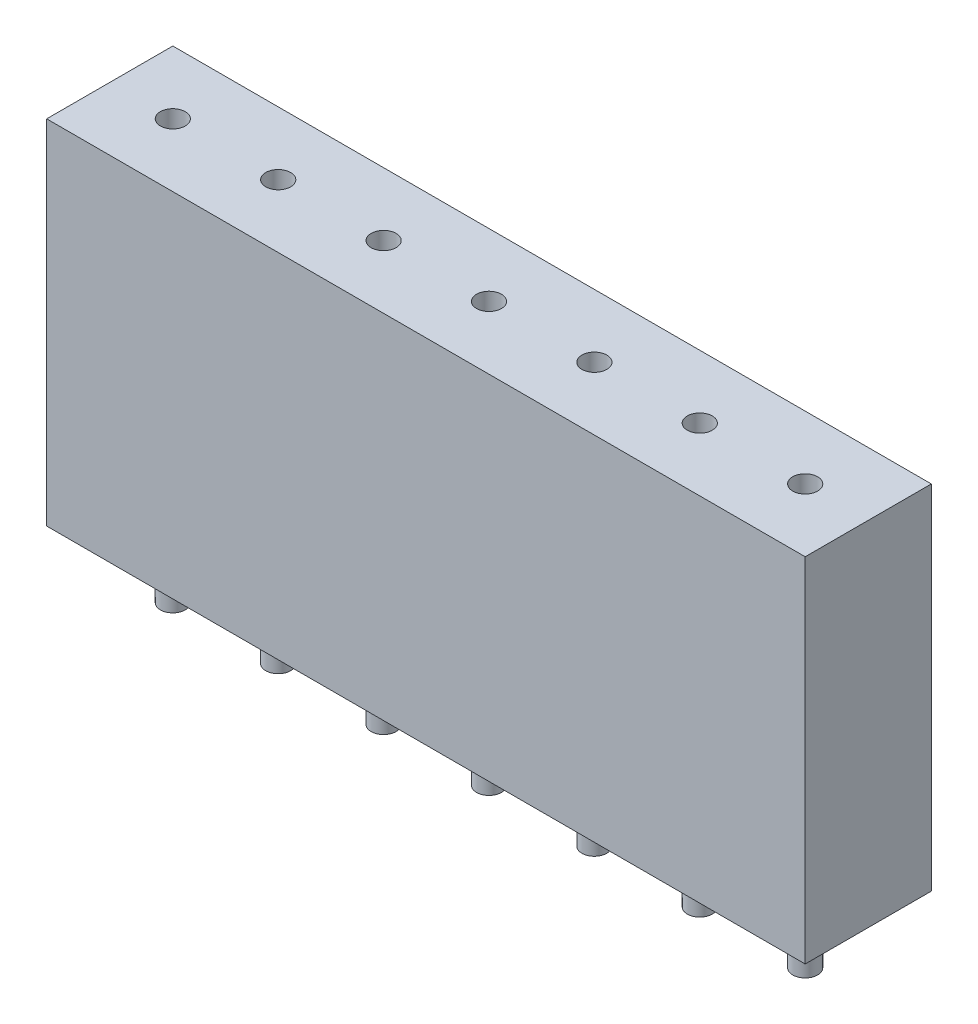
from build123d import *

# Parameters (mm, degrees)
SKETCH_1_W          = 18.28
SKETCH_1_H          = 3.04
EXTRUDE_1_DEPTH     = 8.5
SKETCH_2_R          = 0.3
CUT_EXTRUDE_1_DEPTH = 8.5
SKETCH_3_R          = 0.3
EXTRUDE_2_DEPTH     = 1.6
EXTRUDE_2_2_DEPTH   = 1.6
EXTRUDE_2_3_DEPTH   = 1.6
EXTRUDE_2_4_DEPTH   = 1.6
EXTRUDE_2_5_DEPTH   = 1.6
EXTRUDE_2_6_DEPTH   = 1.6
EXTRUDE_2_7_DEPTH   = 1.6


with BuildPart() as part:
    # Эскиз1 → Бобышка-Вытянуть1 (new body)
    with BuildSketch(Plane(origin=(0, 0, 0), x_dir=(1, 0, 0), z_dir=(0, 1, 0))):
        Rectangle(SKETCH_1_W, SKETCH_1_H)
    extrude(amount=EXTRUDE_1_DEPTH)

    # Эскиз2 → Вырез-Вытянуть1 (cut)
    with BuildSketch(Plane(origin=(0, 8.5, 0), x_dir=(1, 0, 0), z_dir=(0, 1, 0))):
        with Locations((-7.62, 0)):
            Circle(SKETCH_2_R)
        with Locations((-5.08, 0)):
            Circle(SKETCH_2_R)
        with Locations((-2.54, 0)):
            Circle(SKETCH_2_R)
        Circle(SKETCH_2_R)
        with Locations((2.54, 0)):
            Circle(SKETCH_2_R)
        with Locations((5.08, 0)):
            Circle(SKETCH_2_R)
        with Locations((7.62, 0)):
            Circle(SKETCH_2_R)
    extrude(amount=-CUT_EXTRUDE_1_DEPTH, mode=Mode.SUBTRACT)


with BuildPart() as body_2:
    # Эскиз3 → Бобышка-Вытянуть2 (new body)
    with BuildSketch(Plane.XZ):
        with Locations((-7.62, 0)):
            Circle(SKETCH_3_R)
    extrude(amount=EXTRUDE_2_DEPTH)


with BuildPart() as body_3:
    # Эскиз3 → Extrude 2 2 (new body)
    with BuildSketch(Plane.XZ):
        with Locations((-5.08, 0)):
            Circle(SKETCH_3_R)
    extrude(amount=EXTRUDE_2_2_DEPTH)


with BuildPart() as body_4:
    # Эскиз3 → Extrude 2 3 (new body)
    with BuildSketch(Plane.XZ):
        with Locations((-2.54, 0)):
            Circle(SKETCH_3_R)
    extrude(amount=EXTRUDE_2_3_DEPTH)


with BuildPart() as body_5:
    # Эскиз3 → Extrude 2 4 (new body)
    with BuildSketch(Plane.XZ):
        Circle(SKETCH_3_R)
    extrude(amount=EXTRUDE_2_4_DEPTH)


with BuildPart() as body_6:
    # Эскиз3 → Extrude 2 5 (new body)
    with BuildSketch(Plane.XZ):
        with Locations((2.54, 0)):
            Circle(SKETCH_3_R)
    extrude(amount=EXTRUDE_2_5_DEPTH)


with BuildPart() as body_7:
    # Эскиз3 → Extrude 2 6 (new body)
    with BuildSketch(Plane.XZ):
        with Locations((5.08, 0)):
            Circle(SKETCH_3_R)
    extrude(amount=EXTRUDE_2_6_DEPTH)


with BuildPart() as body_8:
    # Эскиз3 → Extrude 2 7 (new body)
    with BuildSketch(Plane.XZ):
        with Locations((7.62, 0)):
            Circle(SKETCH_3_R)
    extrude(amount=EXTRUDE_2_7_DEPTH)


solid = Compound([part.part, body_2.part, body_3.part, body_4.part, body_5.part, body_6.part, body_7.part, body_8.part])
